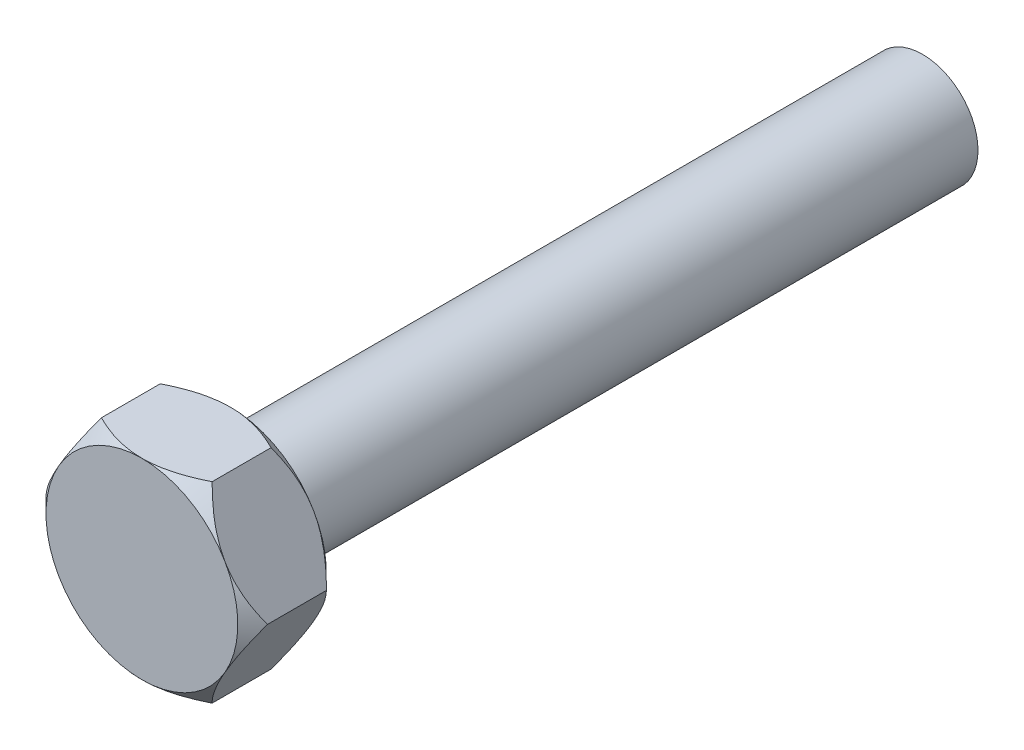
from build123d import *

# Parameters (mm, degrees)
BOSS_EXTRUDE1_DEPTH = 8
SKETCH2_OUTSIDE_W   = 87.056
SKETCH2_OUTSIDE_H   = 81.698
SKETCH2_OUTSIDE_R   = 17.320508076
CUT_EXTRUDE1_DEPTH  = 17
CUT_EXTRUDE1_TAPER  = 45
SKETCH3_R           = 10
BOSS_EXTRUDE2_DEPTH = 125


with BuildPart() as part:
    # Sketch1 → Boss-Extrude1 (new body, symmetric)
    with BuildSketch(Plane.XY):
        Polygon((-10, 17.320508076), (-20, 0), (-10, -17.320508076), (10, -17.320508076), (20, 0), (10, 17.320508076), align=None)
    extrude(amount=BOSS_EXTRUDE1_DEPTH, both=True)

    # Sketch2 outside → Cut-Extrude1 (cut, through all)
    with BuildSketch(Plane.XY.offset(8)):
        Rectangle(SKETCH2_OUTSIDE_W, SKETCH2_OUTSIDE_H)
        Circle(SKETCH2_OUTSIDE_R, mode=Mode.SUBTRACT)
    cut_extrude1 = extrude(amount=-CUT_EXTRUDE1_DEPTH, taper=CUT_EXTRUDE1_TAPER, mode=Mode.SUBTRACT)

    # Mirror1: Cut-Extrude1 across plane
    add(cut_extrude1.mirror(Plane.XY), mode=Mode.SUBTRACT)

    # Sketch3 → Boss-Extrude2 (add)
    with BuildSketch(Plane(origin=(0, 0, -8), x_dir=(-1, 0, 0), z_dir=(0, 0, -1))):
        Circle(SKETCH3_R)
    extrude(amount=BOSS_EXTRUDE2_DEPTH)


solid = part.part
